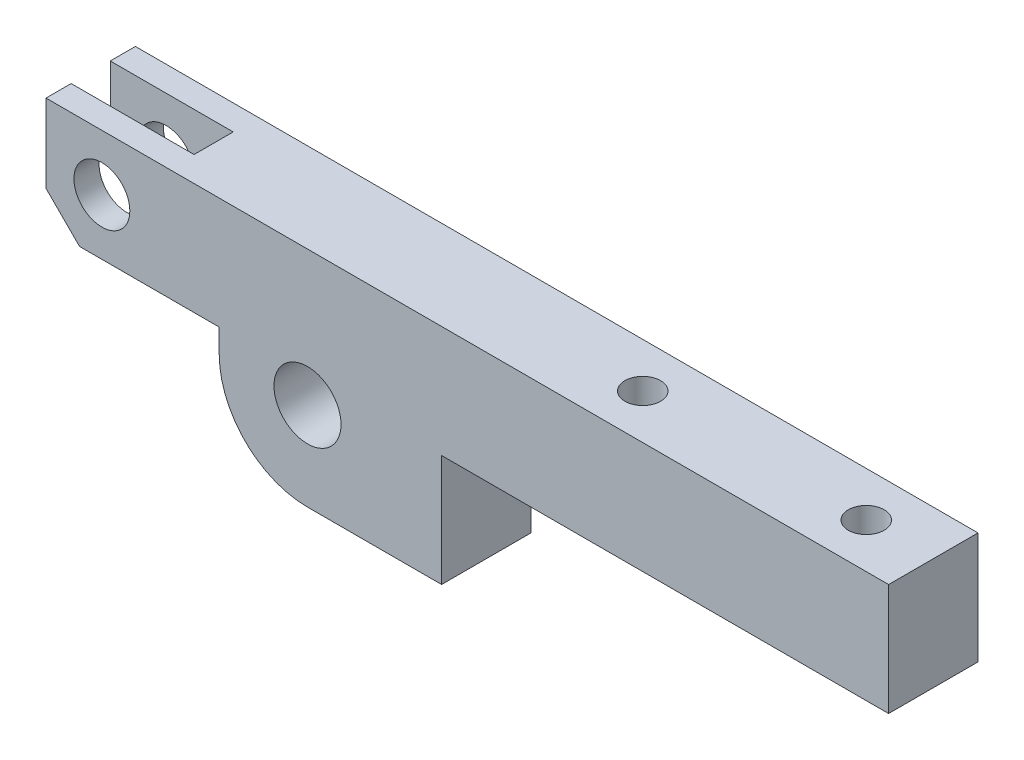
from build123d import *

# Parameters (mm, degrees)
ESQUISSE1_R             = 3
ESQUISSE1_R_2           = 2.5
BASE_EXTRUSION_DEPTH    = 4
CHANFREIN1_SIZE         = 3
ENL_V_MAT_EXTRU_2_DEPTH = 1.75
ESQUISSE7_R             = 1.6
ENL_V_MAT_EXTRU_3_DEPTH = 21


with BuildPart() as part:
    # Esquisse1 → Base-Extrusion (new body, symmetric)
    with BuildSketch(Plane.XY):
        with BuildLine():
            Line((-23.4, 12.1), (52, 12.1))
            Line((52, 12.1), (52, 2.1))
            Line((52, 2.1), (12, 2.1))
            Line((12, 2.1), (12, -7.9))
            Line((12, -7.9), (0, -7.9))
            ThreePointArc((0, -7.9), (-5.586143571, -5.586143571), (-7.9, 0))
            Line((-7.9, 0), (-7.9, 2.1))
            Line((-7.9, 2.1), (-23.4, 2.1))
            Line((-23.4, 2.1), (-23.4, 12.1))
        make_face()
        Circle(ESQUISSE1_R, mode=Mode.SUBTRACT)
        with Locations((-18.4, 7.1)):
            Circle(ESQUISSE1_R_2, mode=Mode.SUBTRACT)
    extrude(amount=BASE_EXTRUSION_DEPTH, both=True)

    # Chanfrein1
    chanfrein1_edges = [part.edges().sort_by_distance(p)[0] for p in [
        (-23.4, 2.1, 0),
    ]]
    chamfer(chanfrein1_edges, length=CHANFREIN1_SIZE)

    # Esquisse2 → Enlèv. mat.-Extru.2 (cut, symmetric)
    with BuildSketch(Plane.XY):
        Polygon((-12.4, 12.1), (-12.4, 2.1), (-20.4, 2.1), (-23.4, 5.1), (-23.4, 12.1), align=None)
    extrude(amount=ENL_V_MAT_EXTRU_2_DEPTH, both=True, mode=Mode.SUBTRACT)

    # Esquisse7 → Enlèv. mat.-Extru.3 (cut, through all)
    with BuildSketch(Plane(origin=(0, 12.1, 0), x_dir=(-1, 0, 0), z_dir=(0, 1, 0))):
        with Locations(Location((-46, 0, 0), (0, 0, 90))):  # turned: the seam where the file's is
            Circle(ESQUISSE7_R)
        with Locations(Location((-26, 0, 0), (0, 0, 90))):  # turned: the seam where the file's is
            Circle(ESQUISSE7_R)
    extrude(amount=-ENL_V_MAT_EXTRU_3_DEPTH, mode=Mode.SUBTRACT)


solid = part.part
